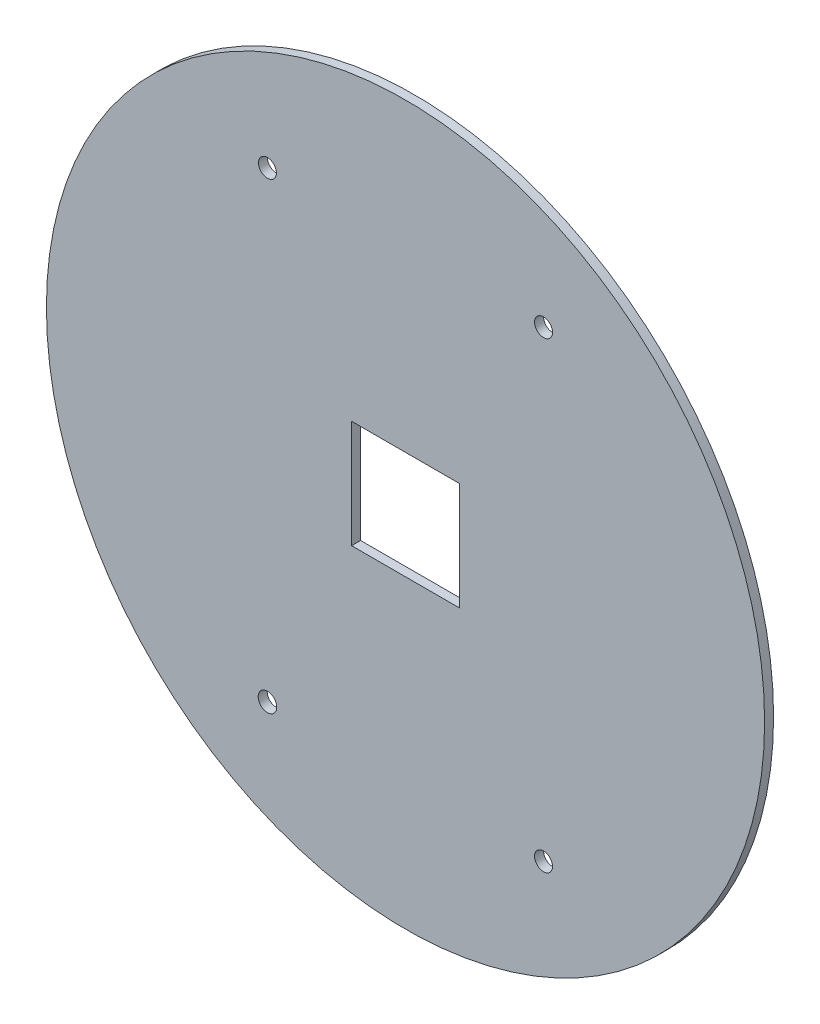
from build123d import *

# Parameters (mm, degrees)
SKETCH1_R           = 200
SKETCH1_R_2         = 5
SKETCH1_R_3         = 5.167590305
SKETCH1_W           = 60
SKETCH1_H           = 60
BOSS_EXTRUDE2_DEPTH = 5


with BuildPart() as part:
    # Sketch1 → Boss-Extrude2 (new body)
    with BuildSketch(Plane.XY):
        Circle(SKETCH1_R)
        with Locations((-76.897220829, 128.789818809)):
            Circle(SKETCH1_R_2, mode=Mode.SUBTRACT)
        with Locations((-76.880166493, -128.8)):
            Circle(SKETCH1_R_3, mode=Mode.SUBTRACT)
        with Locations((76.880166493, 128.8)):
            Circle(SKETCH1_R_2, mode=Mode.SUBTRACT)
        with Locations((76.880166493, -128.8)):
            Circle(SKETCH1_R_2, mode=Mode.SUBTRACT)
        Rectangle(SKETCH1_W, SKETCH1_H, mode=Mode.SUBTRACT)
    extrude(amount=BOSS_EXTRUDE2_DEPTH)


solid = part.part
